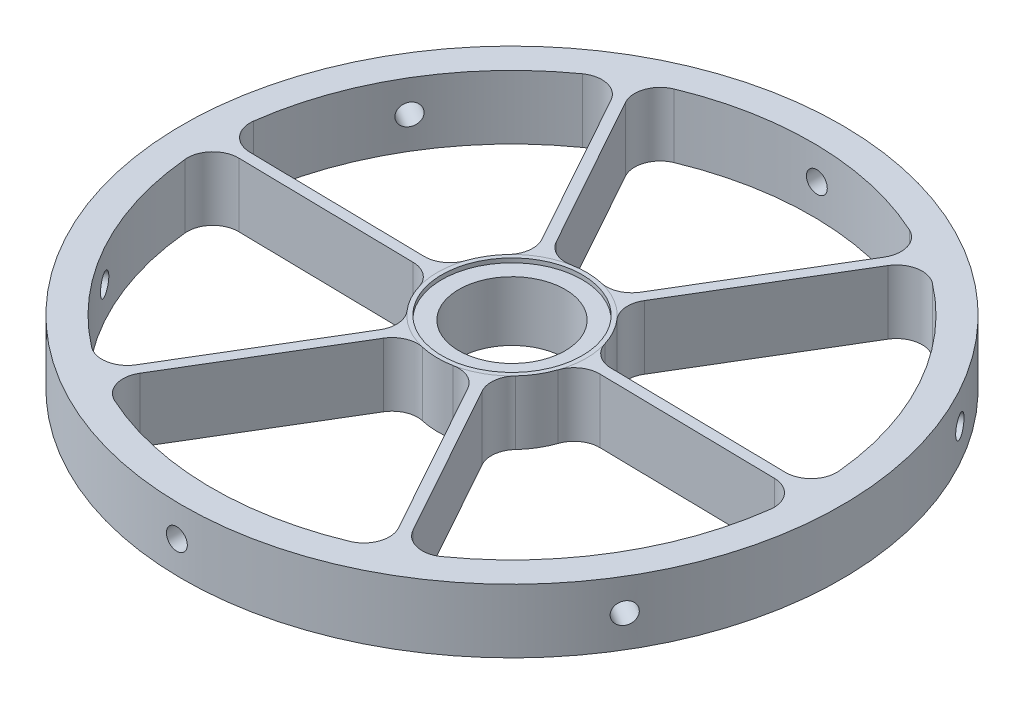
from build123d import *

# Parameters (mm, degrees)
CENTER_RING_R         = 22.225
CENTER_RING_R_2       = 15.875
CENTER_DEPTH          = 9.525
OUTER_R               = 98.425
OUTER_R_2             = 89.535
OUTER_RING_DEPTH      = 9.525
BEAM_START            = -25.456769
BEEAM_W               = 3.175
BEEAM_H               = 19.05
BEAM_DEPTH            = 67.366769
CIRPATTERN1_COUNT     = 6
FILLET1_R             = 7.62
SKETCH27_R            = 20.955
CUT_EXTRUDE3_DEPTH    = 1.27
CUT_EXTRUDE5_START    = -8.946312
SKETCH31_R            = 3.175
CUT_EXTRUDE5_DEPTH    = 8.946312
CIRPATTERN5_COUNT     = 6
BODY_MOVE_COPY7_ANGLE = 31


with BuildPart() as part:
    # Center Ring → Center (new body, symmetric)
    with BuildSketch(Plane(origin=(0, 0, 0), x_dir=(1, 0, 0), z_dir=(0, 1, 0))):
        Circle(CENTER_RING_R)
        Circle(CENTER_RING_R_2, mode=Mode.SUBTRACT)
    extrude(amount=CENTER_DEPTH, both=True)



with BuildPart() as body_2:
    # Outer → Outer Ring (new body, symmetric)
    with BuildSketch(Plane(origin=(0, 0, 0), x_dir=(1, 0, 0), z_dir=(0, 1, 0))):
        Circle(OUTER_R)
        Circle(OUTER_R_2, mode=Mode.SUBTRACT)
    extrude(amount=OUTER_RING_DEPTH, both=True)


with BuildPart() as part_1:
    add(part.part)

    add(body_2.part)  # Beam merges body 2
    # beeam → Beam (add)
    with BuildSketch(Plane.XY.offset(47.625).offset(BEAM_START)):
        Rectangle(BEEAM_W, BEEAM_H)
    beam = extrude(amount=BEAM_DEPTH)

    # CirPattern1: Beam ×6 about axis
    cirpattern1_axis = Axis((0, 0, 0), (0, 1, 0))
    for i in range(1, CIRPATTERN1_COUNT):
        add(beam.rotate(cirpattern1_axis, i * 360 / CIRPATTERN1_COUNT))

    # Fillet1
    fillet1_edges = [part_1.edges().sort_by_distance(p)[0] for p in [
        (-1.5875, 0, 22.168231),
        (-1.5875, 0, 89.520925312),
        (1.5875, 0, 22.168231),
        (1.5875, 0, 89.520925312),
        (-18.404501203, 0, 12.458930829),
        (-76.733645491, 0, 46.135277985),
        (-19.992001203, 0, 9.709300171),
        (-78.321145491, 0, 43.385647328),
        (-19.992001203, 0, -9.709300171),
        (-78.321145491, 0, -43.385647328),
        (-18.404501203, 0, -12.458930829),
        (-76.733645491, 0, -46.135277985),
        (1.5875, 0, -22.168231),
        (1.5875, 0, -89.520925312),
        (-1.5875, 0, -22.168231),
        (-1.5875, 0, -89.520925312),
        (19.992001203, 0, -9.709300171),
        (78.321145491, 0, -43.385647328),
        (18.404501203, 0, -12.458930829),
        (76.733645491, 0, -46.135277985),
        (18.404501203, 0, 12.458930829),
        (76.733645491, 0, 46.135277985),
        (19.992001203, 0, 9.709300171),
        (78.321145491, 0, 43.385647328),
    ]]
    fillet(fillet1_edges, radius=FILLET1_R)

    # Sketch27 → Cut-Extrude3 (cut)
    with BuildSketch(Plane(origin=(0, 9.525, 0), x_dir=(1, 0, 0), z_dir=(0, 1, 0))):
        Circle(SKETCH27_R)
    extrude(amount=-CUT_EXTRUDE3_DEPTH, mode=Mode.SUBTRACT)

    # Sketch31 → Cut-Extrude5 (cut)
    with BuildSketch(Plane(origin=(49.2125, 0, 85.238550367), x_dir=(0, -1, 0), z_dir=(0.5, 0, 0.866025404)).offset(CUT_EXTRUDE5_START)):
        Circle(SKETCH31_R)
    cut_extrude5 = extrude(amount=CUT_EXTRUDE5_DEPTH, mode=Mode.SUBTRACT)

    # CirPattern5: Cut-Extrude5 ×6 about axis
    cirpattern5_axis = Axis((0, 9.525, 0), (0, -1, 0))
    for i in range(1, CIRPATTERN5_COUNT):
        add(cut_extrude5.rotate(cirpattern5_axis, i * 360 / CIRPATTERN5_COUNT), mode=Mode.SUBTRACT)


with BuildPart() as part_2:
    # Body-Move/Copy7: moved
    add(part_1.part.rotate(Axis((0, 0, 0), (0, -1, 0)), BODY_MOVE_COPY7_ANGLE))


solid = part_2.part
